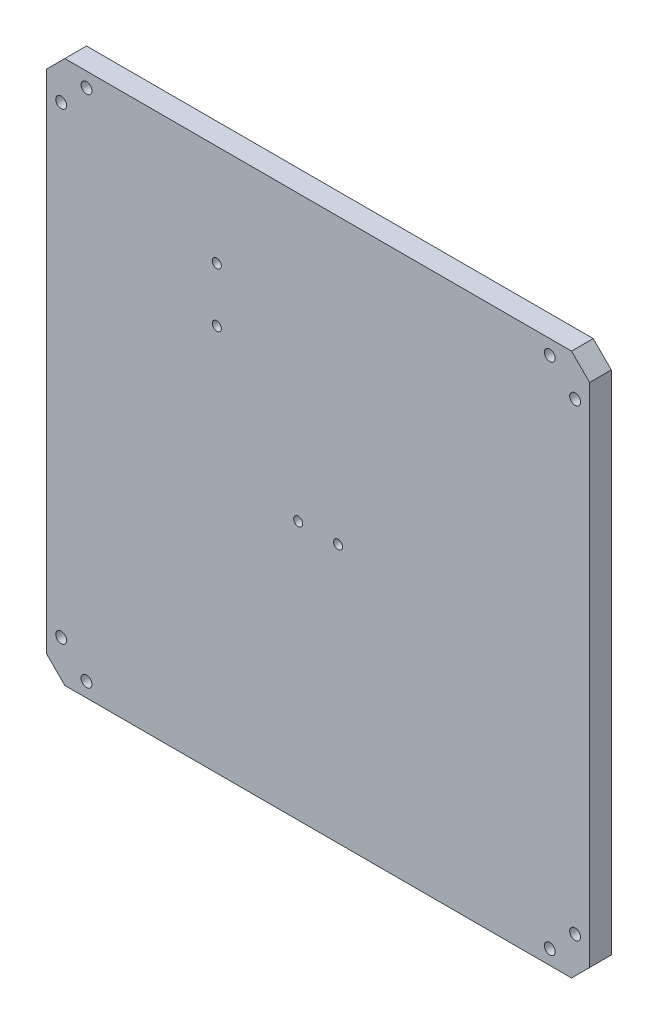
from build123d import *

# Parameters (mm, degrees)
SKETCH_1_W               = 150
SKETCH_1_H               = 150
EXTRUDE_1_DEPTH          = 6
CHAMFER_1_SIZE           = 5
SKETCH_2_R               = 1.5
CUT_EXTRUDE_1_DEPTH      = 10
SKETCH_3_R               = 2.85
CUT_EXTRUDE_2_DEPTH      = 3.2
MIRROR_2_COPY_1_SKETCH_R = 2.85
MIRROR_2_COPY_1_DEPTH    = 3.2
HOLE_WIZARD_M3_1_D       = 2.5
HOLE_WIZARD_M3_1_DEPTH   = 7.5
HOLE_WIZARD_M3_1_TIP     = 0.751075774
HOLE_WIZARD_M3_2_D       = 2.5
HOLE_WIZARD_M3_2_DEPTH   = 7.5
HOLE_WIZARD_M3_2_TIP     = 0.751075774


with BuildPart() as part:
    # 草图1 → 凸台-拉伸1 (new body)
    with BuildSketch(Plane.XY):
        Rectangle(SKETCH_1_W, SKETCH_1_H)
    extrude(amount=EXTRUDE_1_DEPTH)

    # 倒角1
    chamfer_1_edges = [part.edges().sort_by_distance(p)[0] for p in [
        (-75, 75, 3),
        (75, 75, 3),
        (75, -75, 3),
        (-75, -75, 3),
    ]]
    chamfer(chamfer_1_edges, length=CHAMFER_1_SIZE)

    # 草图2 → 切除-拉伸1 (cut)
    with BuildSketch(Plane.XY.offset(6)):
        with Locations((64, 71)):
            Circle(SKETCH_2_R)
        with Locations((71, 64)):
            Circle(SKETCH_2_R)
        with Locations((-71, 64)):
            Circle(SKETCH_2_R)
        with Locations((-64, 71)):
            Circle(SKETCH_2_R)
    cut_extrude_1 = extrude(amount=-CUT_EXTRUDE_1_DEPTH, mode=Mode.SUBTRACT)

    # 草图3 → 切除-拉伸2 (cut)
    with BuildSketch(Plane(origin=(0, 0, 0), x_dir=(-1, 0, 0), z_dir=(0, 0, -1))):
        with Locations((64, 71)):
            Circle(SKETCH_3_R)
        with Locations((71, 64)):
            Circle(SKETCH_3_R)
    cut_extrude_2 = extrude(amount=-CUT_EXTRUDE_2_DEPTH, mode=Mode.SUBTRACT)

    # 镜向1: 切除-拉伸2 across plane
    add(cut_extrude_2.mirror(Plane(origin=(0, 0, 0), x_dir=(0, 0, 1), z_dir=(1, 0, 0))), mode=Mode.SUBTRACT)

    # 镜向2: 切除-拉伸1, 切除-拉伸2 across plane
    add(cut_extrude_1.mirror(Plane.ZX), mode=Mode.SUBTRACT)
    add(cut_extrude_2.mirror(Plane.ZX), mode=Mode.SUBTRACT)

    # 镜向2 copy 1 sketch → 镜向2 copy 1 (cut)
    with BuildSketch(Plane(origin=(0, 0, 0), x_dir=(1, 0, 0), z_dir=(0, 0, -1))):
        with Locations((64, 71)):
            Circle(MIRROR_2_COPY_1_SKETCH_R)
        with Locations((71, 64)):
            Circle(MIRROR_2_COPY_1_SKETCH_R)
    extrude(amount=-MIRROR_2_COPY_1_DEPTH, mode=Mode.SUBTRACT)

    # M3 螺纹孔1
    with Locations(Plane.XY.offset(6)):
        with Locations((-5.5, -3.5), (5.5, -3.5)):
            Hole(HOLE_WIZARD_M3_1_D / 2, depth=HOLE_WIZARD_M3_1_DEPTH)
            with Locations((0, 0, -(HOLE_WIZARD_M3_1_DEPTH + HOLE_WIZARD_M3_1_TIP / 2))):  # 118° drill point
                Cone(0, HOLE_WIZARD_M3_1_D / 2, HOLE_WIZARD_M3_1_TIP, mode=Mode.SUBTRACT)

    # M3 螺纹孔2
    with Locations(Plane.XY.offset(6)):
        with Locations((-28, 47), (-28, 32)):
            Hole(HOLE_WIZARD_M3_2_D / 2, depth=HOLE_WIZARD_M3_2_DEPTH)
            with Locations((0, 0, -(HOLE_WIZARD_M3_2_DEPTH + HOLE_WIZARD_M3_2_TIP / 2))):  # 118° drill point
                Cone(0, HOLE_WIZARD_M3_2_D / 2, HOLE_WIZARD_M3_2_TIP, mode=Mode.SUBTRACT)


solid = part.part
